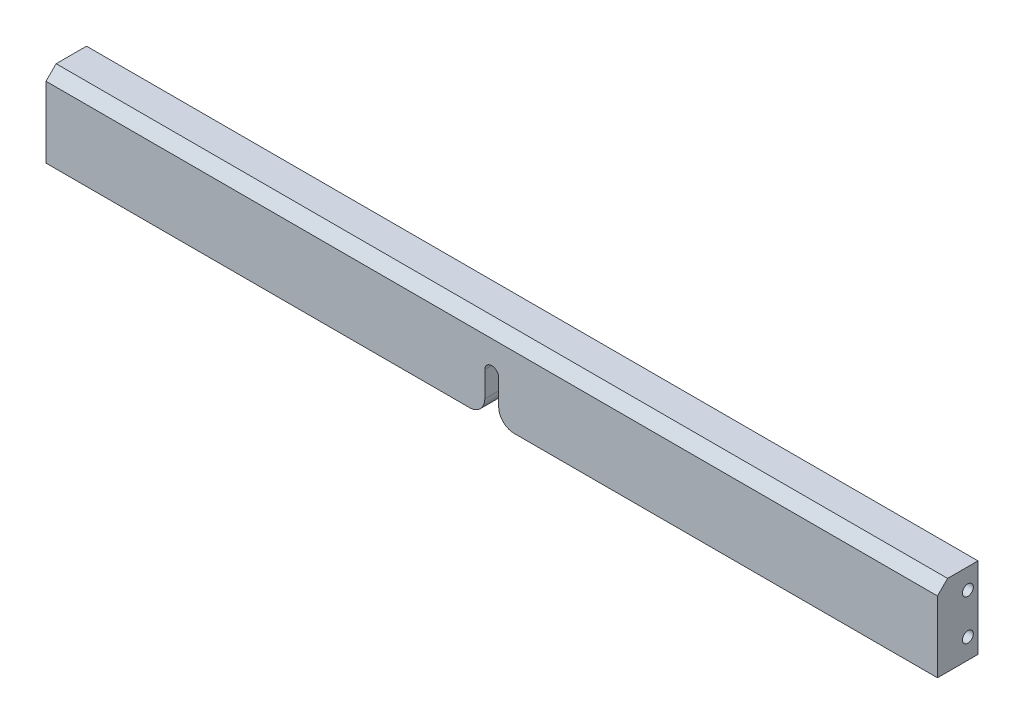
from build123d import *

# Parameters (mm, degrees)
SKETCH1_W                  = 558.8
SKETCH1_H                  = 50.8
EXTRUDE1_DEPTH             = 12.7
CUT_EXTRUDE3_REACH         = 27.4
FILLET2_R                  = 9.525
M8X1_25_TAPPED_HOLE1_D     = 6.8
M8X1_25_TAPPED_HOLE1_DEPTH = 19.812
M8X1_25_TAPPED_HOLE1_TIP   = 2.042926105
M8X1_25_TAPPED_HOLE2_D     = 6.8
M8X1_25_TAPPED_HOLE2_DEPTH = 19.812
M8X1_25_TAPPED_HOLE2_TIP   = 2.042926105
CHAMFER1_SIZE              = 6.35


with BuildPart() as part:
    # Sketch1 → Extrude1 (new body, symmetric)
    with BuildSketch(Plane.XY):
        Rectangle(SKETCH1_W, SKETCH1_H)
    extrude(amount=EXTRUDE1_DEPTH, both=True)

    # Sketch4 → Cut-Extrude3 (cut, up to next)
    with BuildSketch(Plane.XY.offset(12.7), mode=Mode.PRIVATE) as cut_extrude3_sk1:
        with BuildLine():
            Line((-4.365625, -25.4), (-4.365625, 0))
            ThreePointArc((-4.365625, 0), (0, 4.365625), (4.365625, 0))
            Line((4.365625, 0), (4.365625, -25.4))
            ThreePointArc((4.365625, -25.4), (0, -29.765625), (-4.365625, -25.4))
        make_face()
    cut_extrude3_tool1 = extrude(cut_extrude3_sk1.sketch, amount=-CUT_EXTRUDE3_REACH, mode=Mode.PRIVATE) & part.part
    add(cut_extrude3_tool1.solids().sort_by_distance((0, -12.7, 12.7))[0], mode=Mode.SUBTRACT)

    # Fillet2
    fillet2_edges = [part.edges().sort_by_distance(p)[0] for p in [
        (-4.365625, -25.4, 0),
        (4.365625, -25.4, 0),
    ]]
    fillet(fillet2_edges, radius=FILLET2_R)

    # M8x1.25 Tapped Hole1
    with Locations(Plane(origin=(279.4, 0, 0), x_dir=(0, 0, -1), z_dir=(1, 0, 0))):
        with Locations((6.35, 12.7), (6.35, -12.7)):
            Hole(M8X1_25_TAPPED_HOLE1_D / 2, depth=M8X1_25_TAPPED_HOLE1_DEPTH)
            with Locations((0, 0, -(M8X1_25_TAPPED_HOLE1_DEPTH + M8X1_25_TAPPED_HOLE1_TIP / 2))):  # 118° drill point
                Cone(0, M8X1_25_TAPPED_HOLE1_D / 2, M8X1_25_TAPPED_HOLE1_TIP, mode=Mode.SUBTRACT)

    # M8x1.25 Tapped Hole2
    with Locations(Plane.ZY.offset(279.4)):
        with Locations((-6.35, 12.7), (-6.35, -12.7)):
            Hole(M8X1_25_TAPPED_HOLE2_D / 2, depth=M8X1_25_TAPPED_HOLE2_DEPTH)
            with Locations((0, 0, -(M8X1_25_TAPPED_HOLE2_DEPTH + M8X1_25_TAPPED_HOLE2_TIP / 2))):  # 118° drill point
                Cone(0, M8X1_25_TAPPED_HOLE2_D / 2, M8X1_25_TAPPED_HOLE2_TIP, mode=Mode.SUBTRACT)

    # Chamfer1
    chamfer1_edges = [part.edges().sort_by_distance(p)[0] for p in [
        (0, 25.4, 12.7),
    ]]
    chamfer(chamfer1_edges, length=CHAMFER1_SIZE)


solid = part.part
